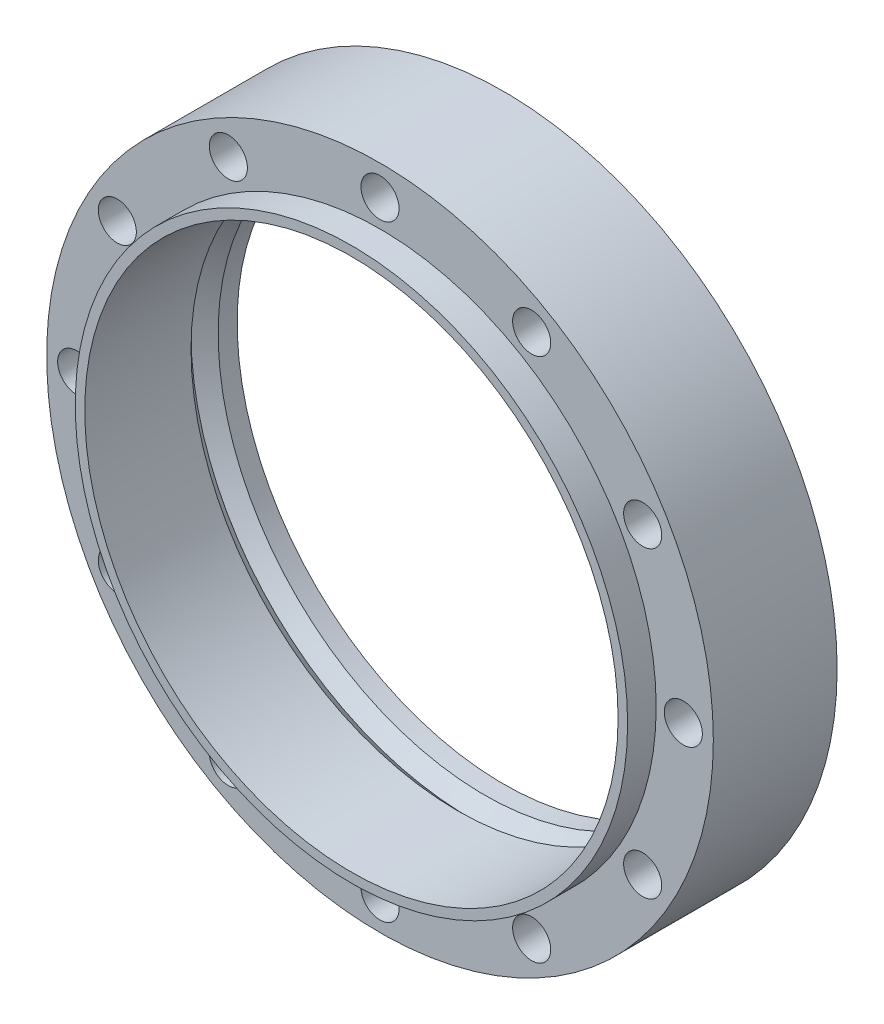
from build123d import *

# Parameters (mm, degrees)
SKETCH_1_R               = 35
EXTRUDE_1_DEPTH          = 16
SKETCH_2_R               = 35
SKETCH_2_R_2             = 29
CUT_EXTRUDE_1_DEPTH      = 3
SKETCH_3_R               = 28
CUT_EXTRUDE_2_DEPTH      = 17
SKETCH_4_R               = 2
CUT_EXTRUDE_3_DEPTH      = 14
PATTERN_CIRCULAR_1_COUNT = 12


with BuildPart() as part:
    # 草图1 → 凸台-拉伸1 (new body)
    with BuildSketch(Plane.XY):
        Circle(SKETCH_1_R)
    extrude(amount=EXTRUDE_1_DEPTH)

    # 草图2 → 切除-拉伸1 (cut)
    with BuildSketch(Plane.XY.offset(16)):
        Circle(SKETCH_2_R)
        Circle(SKETCH_2_R_2, mode=Mode.SUBTRACT)
    extrude(amount=-CUT_EXTRUDE_1_DEPTH, mode=Mode.SUBTRACT)

    # 草图3 → 切除-拉伸2 (cut, through all)
    with BuildSketch(Plane.XY.offset(16)):
        Circle(SKETCH_3_R)
    extrude(amount=-CUT_EXTRUDE_2_DEPTH, mode=Mode.SUBTRACT)

    # 草图4 → 切除-拉伸3 (cut, through all)
    with BuildSketch(Plane.XY.offset(13)):
        with Locations((0, 31.847890671)):
            Circle(SKETCH_4_R)
    cut_extrude_3 = extrude(amount=-CUT_EXTRUDE_3_DEPTH, mode=Mode.SUBTRACT)

    # 阵列(圆周)1: 切除-拉伸3 ×12 about axis
    pattern_circular_1_axis = Axis((0, 0, 0), (0, 0, 1))
    for i in range(1, PATTERN_CIRCULAR_1_COUNT):
        add(cut_extrude_3.rotate(pattern_circular_1_axis, i * 360 / PATTERN_CIRCULAR_1_COUNT), mode=Mode.SUBTRACT)

    # 草图5 → 切除-旋转3 (revolve, cut)
    with BuildSketch(Plane(origin=(0, 0, 0), x_dir=(0, 0, -1), z_dir=(1, 0, 0))):
        Polygon((-4.855352657, 27.98817223), (-1.98280478, 27.986477885), (-3.419925891, 29.423598996), align=None)
    revolve(axis=Axis((0, 0, 0), (0, 0, 1)), mode=Mode.SUBTRACT)


solid = part.part
